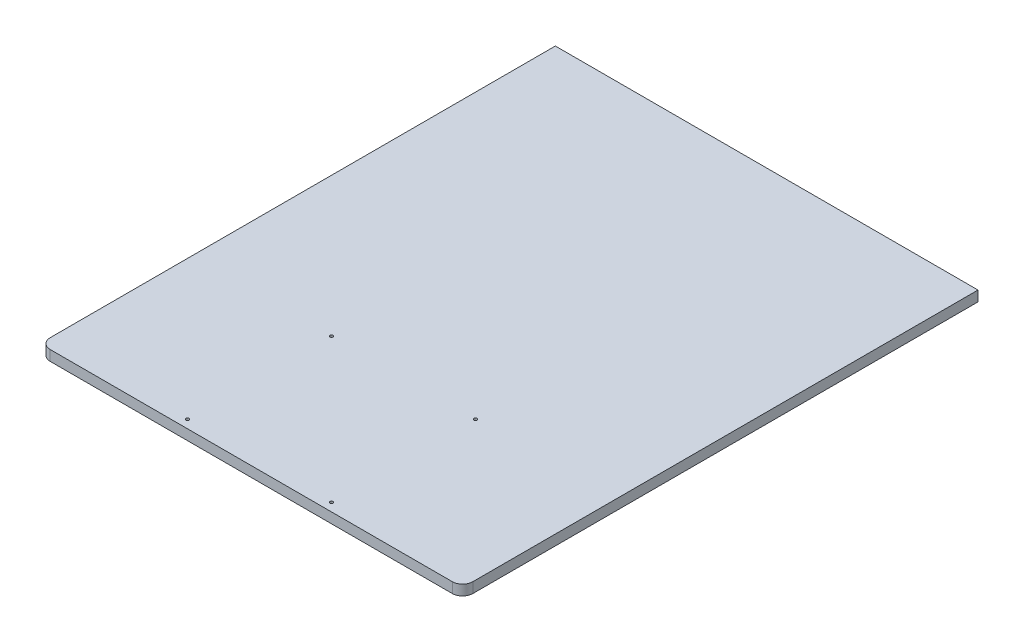
from build123d import *

# Parameters (mm, degrees)
SKETCH1_W           = 410
SKETCH1_H           = 500
SKETCH1_R           = 1.5
BOSS_EXTRUDE1_DEPTH = 10
FILLET1_R           = 10


with BuildPart() as part:
    # Sketch1 → Boss-Extrude1 (new body)
    with BuildSketch(Plane(origin=(0, 0, 0), x_dir=(1, 0, 0), z_dir=(0, 1, 0))):
        Rectangle(SKETCH1_W, SKETCH1_H)
        with Locations((-69.851403599, -242)):
            Circle(SKETCH1_R, mode=Mode.SUBTRACT)
        with Locations((-69.851403599, -102.297192802)):
            Circle(SKETCH1_R, mode=Mode.SUBTRACT)
        with Locations((69.851403599, -102.297192802)):
            Circle(SKETCH1_R, mode=Mode.SUBTRACT)
        with Locations((69.851403599, -242)):
            Circle(SKETCH1_R, mode=Mode.SUBTRACT)
    extrude(amount=BOSS_EXTRUDE1_DEPTH)

    # Fillet1
    fillet1_edges = [part.edges().sort_by_distance(p)[0] for p in [
        (205, 5, 250),
        (-205, 5, 250),
    ]]
    fillet(fillet1_edges, radius=FILLET1_R)


solid = part.part
